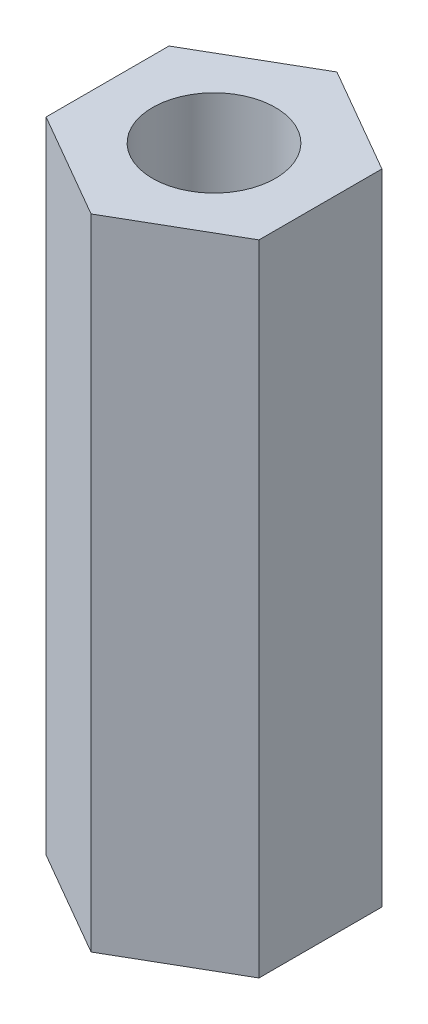
from build123d import *

# Parameters (mm, degrees)
ESQUISSE1_R      = 2.5
EXTRUSION1_DEPTH = 26


with BuildPart() as part:
    # Esquisse1 → Extrusion1 (new body)
    with BuildSketch(Plane(origin=(0, 0, 0), x_dir=(1, 0, 0), z_dir=(0, 1, 0))):
        Polygon((0, 5), (-4.330127019, 2.5), (-4.330127019, -2.5), (0, -5), (4.330127019, -2.5), (4.330127019, 2.5), align=None)
        Circle(ESQUISSE1_R, mode=Mode.SUBTRACT)
    extrude(amount=EXTRUSION1_DEPTH)


solid = part.part
